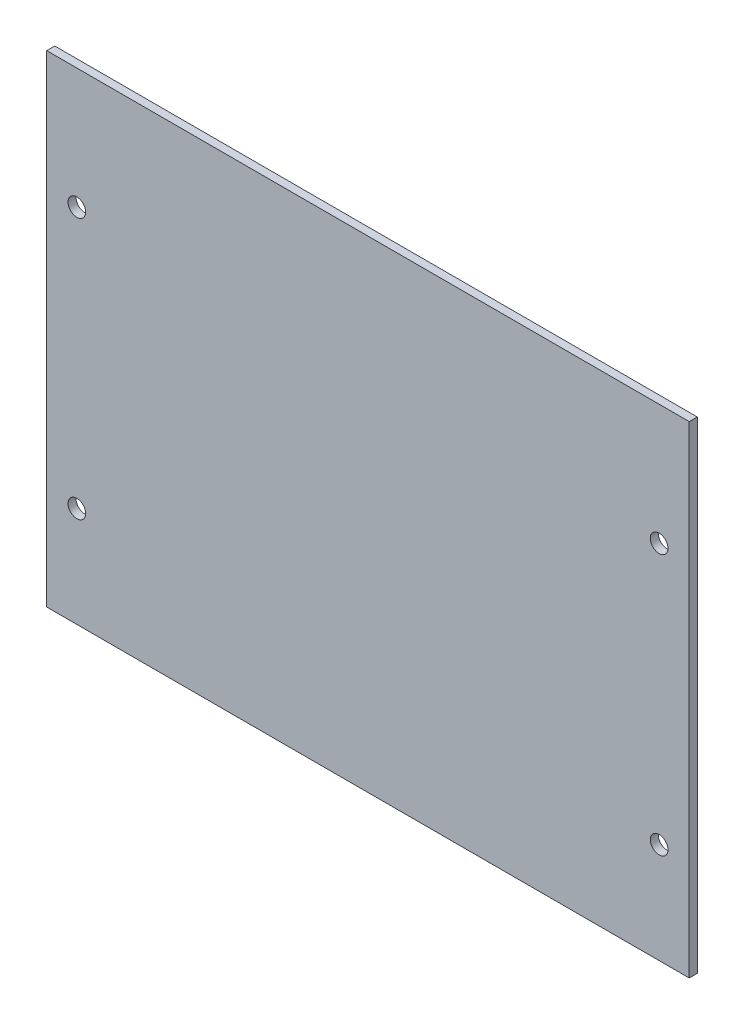
from build123d import *

# Parameters (mm, degrees)
SKETCH_1_W          = 160
SKETCH_1_H          = 120
EXTRUDE_1_DEPTH     = 2
SKETCH_2_R          = 2.2
CUT_EXTRUDE_1_DEPTH = 2


with BuildPart() as part:
    # ｽｹｯﾁ1 → ﾎﾞｽ - 押し出し1 (new body)
    with BuildSketch(Plane.XY):
        Rectangle(SKETCH_1_W, SKETCH_1_H)
    extrude(amount=EXTRUDE_1_DEPTH)

    # ｽｹｯﾁ2 → ｶｯﾄ - 押し出し1 (cut)
    with BuildSketch(Plane.XY.offset(2)):
        with Locations((-72.5, -35)):
            Circle(SKETCH_2_R)
        with Locations((-72.5, 30)):
            Circle(SKETCH_2_R)
        with Locations((72.5, -35)):
            Circle(SKETCH_2_R)
        with Locations((72.5, 30)):
            Circle(SKETCH_2_R)
    extrude(amount=-CUT_EXTRUDE_1_DEPTH, mode=Mode.SUBTRACT)


solid = part.part
